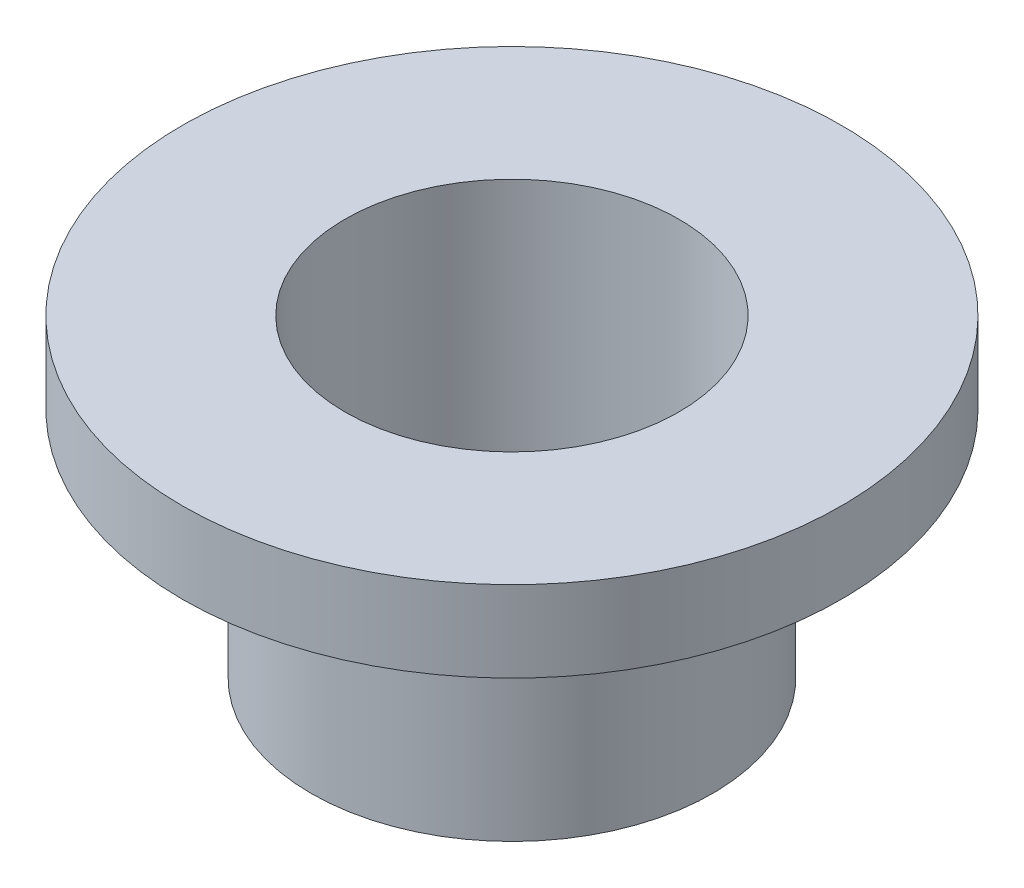
from build123d import *


with BuildPart() as part:
    # Sketch1 → Revolve1 (revolve)
    with BuildSketch(Plane.XY):
        Polygon((3.302, 0), (3.302, 6.1976), (6.5151, 6.1976), (6.5151, 4.5974), (3.96875, 4.5974), (3.96875, 0), align=None)
    revolve(axis=Axis((0, 29.183344121, 0), (0, -1, 0)))


solid = part.part
